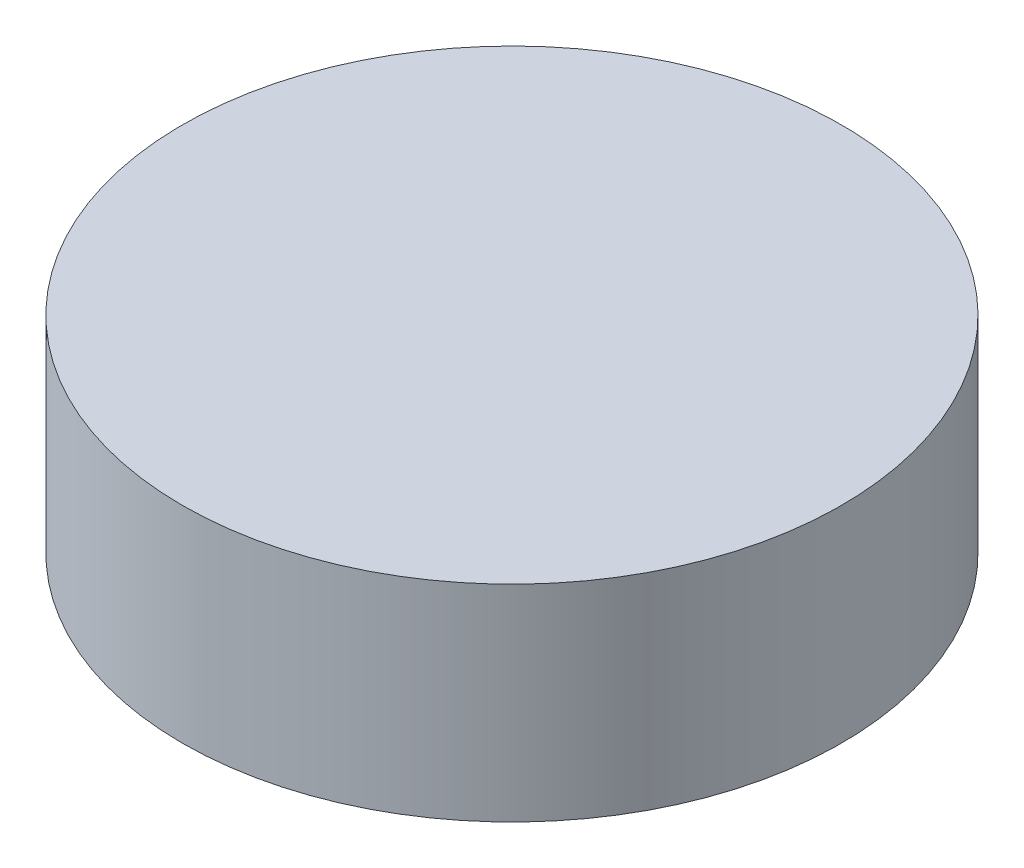
from build123d import *

# Parameters (mm, degrees)
MAGNET_SKETCH_R           = 4
MAGENT_BOSS_EXTRUDE_DEPTH = 2.5


with BuildPart() as part:
    # Magnet Sketch → Magent Boss-Extrude (new body)
    with BuildSketch(Plane(origin=(0, 0, 0), x_dir=(1, 0, 0), z_dir=(0, 1, 0))):
        Circle(MAGNET_SKETCH_R)
    extrude(amount=MAGENT_BOSS_EXTRUDE_DEPTH)


solid = part.part
